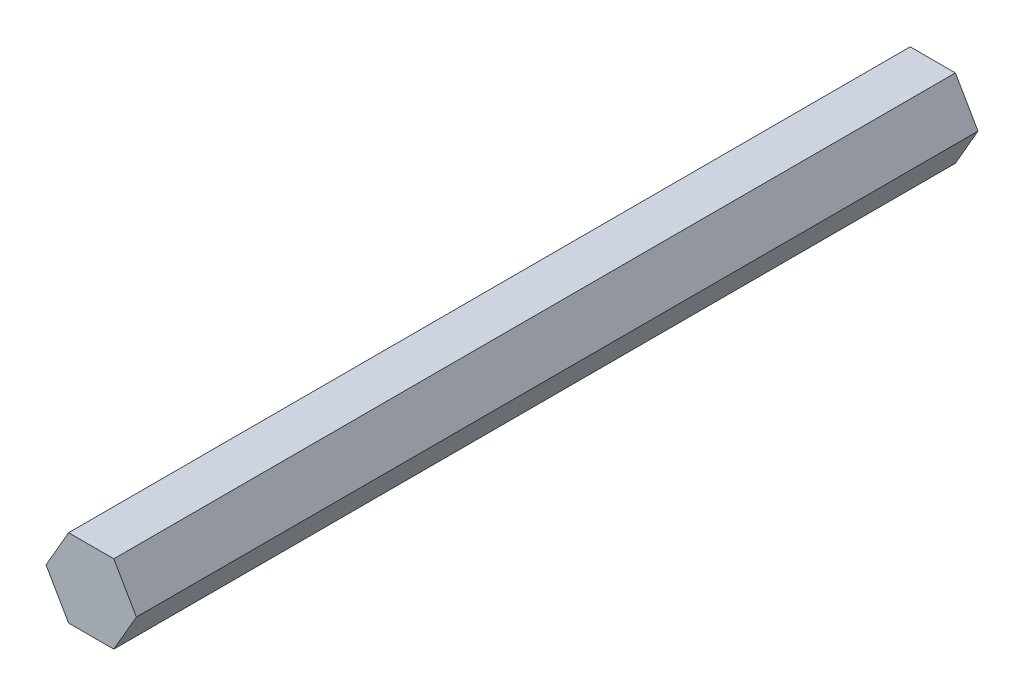
from build123d import *

# Parameters (mm, degrees)
BOSS_EXTRUDE1_DEPTH        = 136.525
F_10_32_TAPPED_HOLE1_D     = 4.0386
F_10_32_TAPPED_HOLE1_DEPTH = 12.7
F_10_32_TAPPED_HOLE1_TIP   = 1.213317848


with BuildPart() as part:
    # Sketch1 → Boss-Extrude1 (new body)
    with BuildSketch(Plane.XY):
        Polygon((3.666174209, 6.35), (-3.666174209, 6.35), (-7.332348419, 0), (-3.666174209, -6.35), (3.666174209, -6.35), (7.332348419, 0), align=None)
    extrude(amount=BOSS_EXTRUDE1_DEPTH)

    # #10-32 Tapped Hole1
    with Locations(Plane(origin=(0, 0, 0), x_dir=(-1, 0, 0), z_dir=(0, 0, -1))):
        with Locations((0, 0)):
            Hole(F_10_32_TAPPED_HOLE1_D / 2, depth=F_10_32_TAPPED_HOLE1_DEPTH)
            with Locations((0, 0, -(F_10_32_TAPPED_HOLE1_DEPTH + F_10_32_TAPPED_HOLE1_TIP / 2))):  # 118° drill point
                Cone(0, F_10_32_TAPPED_HOLE1_D / 2, F_10_32_TAPPED_HOLE1_TIP, mode=Mode.SUBTRACT)


solid = part.part
